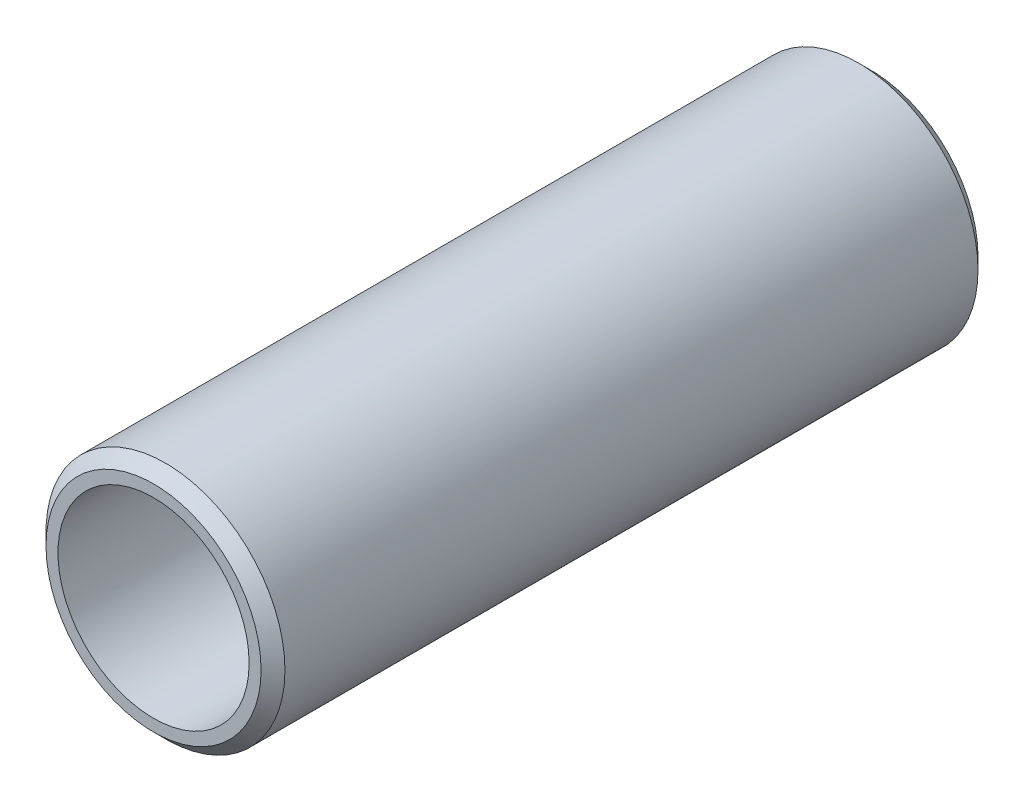
from build123d import *

# Parameters (mm, degrees)
SKETCH1_R           = 5
SKETCH1_R_2         = 4
EXTRUDE_THIN1_DEPTH = 30
CHAMFER1_SIZE       = 0.5


with BuildPart() as part:
    # Sketch1 → Extrude-Thin1 (new body)
    with BuildSketch(Plane.XY):
        Circle(SKETCH1_R)
        Circle(SKETCH1_R_2, mode=Mode.SUBTRACT)
    extrude(amount=EXTRUDE_THIN1_DEPTH)

    # Chamfer1
    chamfer1_edges = [part.edges().sort_by_distance(p)[0] for p in [
        (-5, 0, 0),
        (-5, 0, 30),
    ]]
    chamfer(chamfer1_edges, length=CHAMFER1_SIZE)


solid = part.part
